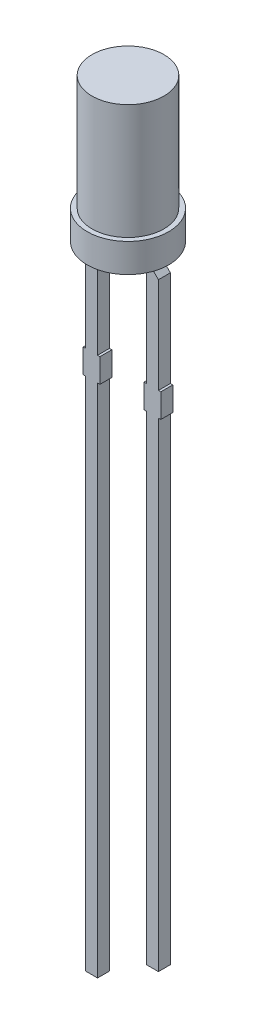
from build123d import *

# Parameters (mm, degrees)
SKETCH1_R          = 1.7
EXTRUDE1_DEPTH     = 1.2
SKETCH2_W          = 0.5
SKETCH2_H          = 1
SKETCH2_W_2        = 0.1
SKETCH2_H_2        = 21.5
SKETCH2_H_3        = 20
EXTRUDE2_DEPTH     = 0.25
SKETCH2_3_W        = 1.5
SKETCH2_3_H        = 4.8
SKETCH3_W          = 0.012658228
SKETCH3_H          = 0.013291139
CUT_EXTRUDE1_DEPTH = 0.01


with BuildPart() as part:
    # Sketch1 → Extrude1 (new body)
    with BuildSketch(Plane(origin=(0, 0, 0), x_dir=(1, 0, 0), z_dir=(0, 1, 0))):
        with Locations(Location((0, 0, 0), (0, 0, 270))):  # turned: the seam where the file's is
            Circle(SKETCH1_R)
    extrude(amount=EXTRUDE1_DEPTH)

    # Sketch2 → Extrude2 (add, symmetric)
    with BuildSketch(Plane.XY):
        Polygon((-0.52, -0.5), (-0.52, 0), (-1.02, 0), (-1.52, -0.5), (-1.52, -4.5), (-1.02, -4.5), (-1.02, -0.5), align=None)
        with Locations((-1.27, -5)):
            Rectangle(SKETCH2_W, SKETCH2_H)
        with Locations((-0.97, -5)):
            Rectangle(SKETCH2_W_2, SKETCH2_H)
        with Locations((-1.57, -5)):
            Rectangle(SKETCH2_W_2, SKETCH2_H)
        with Locations((-1.27, -16.25)):
            Rectangle(SKETCH2_W, SKETCH2_H_2)
        with Locations((1.27, -5)):
            Rectangle(SKETCH2_W, SKETCH2_H)
        Polygon((1.02, -0.5), (1.02, -4.5), (1.52, -4.5), (1.52, -0.5), (1.02, 0), (0.52, 0), (0.52, -0.5), align=None)
        with Locations((1.57, -5)):
            Rectangle(SKETCH2_W_2, SKETCH2_H)
        with Locations((0.97, -5)):
            Rectangle(SKETCH2_W_2, SKETCH2_H)
        with Locations((1.27, -15.5)):
            Rectangle(SKETCH2_W, SKETCH2_H_3)
    extrude(amount=EXTRUDE2_DEPTH, both=True)

    # Sketch2_3 → Revolve1 (revolve)
    with BuildSketch(Plane.XY, mode=Mode.PRIVATE) as revolve1_sk:
        with Locations((0.75, 3.6)):
            Rectangle(SKETCH2_3_W, SKETCH2_3_H)
    revolve(revolve1_sk.sketch.rotate(Axis((0, 1.2, 0), (0, 1, 0)), 270), axis=Axis((0, 1.2, 0), (0, 1, 0)))  # turned: the seam where the file's is

    # Sketch3 → Cut-Extrude1 (cut)
    with BuildSketch(Plane.XZ):
        Polygon((0.287314412, 0.212658228), (0.299043051, 0.25), (0.311414491, 0.25), (0.319622561, 0.224831883), (0.327385615, 0.25), (0.340251517, 0.25), (0.351871374, 0.212658228), (0.339282371, 0.212658228), (0.33278514, 0.238399921), (0.32457707, 0.212658228), (0.313827466, 0.212658228), (0.305668843, 0.238399921), (0.299260615, 0.212658228), align=None)
        Polygon((0.220225805, 0.212658228), (0.231954444, 0.25), (0.244325884, 0.25), (0.252533953, 0.224831883), (0.260297007, 0.25), (0.273162909, 0.25), (0.284782767, 0.212658228), (0.272193763, 0.212658228), (0.265696532, 0.238399921), (0.257488463, 0.212658228), (0.246738858, 0.212658228), (0.238580235, 0.238399921), (0.232172007, 0.212658228), align=None)
        Polygon((0.153137197, 0.212658228), (0.164865836, 0.25), (0.177237276, 0.25), (0.185445346, 0.224831883), (0.193208399, 0.25), (0.206074301, 0.25), (0.217694159, 0.212658228), (0.205105156, 0.212658228), (0.198607925, 0.238399921), (0.190399855, 0.212658228), (0.179650251, 0.212658228), (0.171491627, 0.238399921), (0.165083399, 0.212658228), align=None)
        with Locations((0.139213146, 0.24335443)):
            Rectangle(SKETCH3_W, SKETCH3_H)
        with BuildLine():
            add(Edge.make_bspline(
                [(0.080985298, 0.234414557), (0.081003562, 0.235025614), (0.081039427, 0.236225526), (0.081344008, 0.237979509), (0.08184177, 0.239641151), (0.082523939, 0.241222509), (0.083430933, 0.242700192), (0.08450844, 0.244109475), (0.085814397, 0.245401456), (0.087282915, 0.246620837), (0.088931879, 0.247712034), (0.09073319, 0.248662103), (0.09266835, 0.249474462), (0.09474536, 0.250140307), (0.096968149, 0.250635691), (0.099327037, 0.25099735), (0.101823712, 0.251234103), (0.103535505, 0.251255074), (0.104412909, 0.251265823)],
                knots=[0, 0, 0, 0, 0.907421153, 1.781872267, 2.635683434, 3.480115191, 4.332689235, 5.205575272, 6.109500117, 7.055808355, 8.037942167, 9.041423561, 10.07750834, 11.152467461, 12.277657752, 13.45734338, 14.696726425, 16, 16, 16, 16], degree=3))
            add(Edge.make_bspline(
                [(0.104412909, 0.251265823), (0.105421901, 0.25125219), (0.107375994, 0.251225789), (0.110209778, 0.251033102), (0.112841512, 0.250689127), (0.115290385, 0.250210837), (0.117592536, 0.249609194), (0.119809208, 0.248963872), (0.121949854, 0.248231582), (0.1233364, 0.247681514), (0.124023273, 0.247409019)],
                knots=[0, 0, 0, 0, 1.203182053, 2.33017619, 3.384818652, 4.366208123, 5.30340534, 6.221361684, 7.118890722, 8, 8, 8, 8], degree=3))
            Line((0.124023273, 0.247409019), (0.124023273, 0.235443038))
            Line((0.124023273, 0.235443038), (0.122599222, 0.235443038))
            add(Edge.make_bspline(
                [(0.122599222, 0.235443038), (0.121916441, 0.235983519), (0.120554886, 0.237061309), (0.118341407, 0.238445486), (0.116011901, 0.239631991), (0.113592704, 0.240623303), (0.11114202, 0.24141111), (0.108707486, 0.241974562), (0.106322995, 0.242344245), (0.104743834, 0.242385025), (0.103967893, 0.242405063)],
                knots=[0, 0, 0, 0, 1.030738938, 2.055426519, 3.085610749, 4.123842265, 5.148648843, 6.130724483, 7.081507926, 8, 8, 8, 8], degree=3))
            add(Edge.make_bspline(
                [(0.103967893, 0.242405063), (0.10375352, 0.242404413), (0.103294564, 0.242403021), (0.10255999, 0.242342363), (0.101731818, 0.242278441), (0.100841449, 0.242180384), (0.099947847, 0.242064812), (0.099117723, 0.241891578), (0.098367342, 0.241707002), (0.097914007, 0.24152337), (0.097698115, 0.241435918)],
                knots=[0, 0, 0, 0, 0.806537132, 1.726733348, 2.77251655, 3.932999672, 5.098049949, 6.161349231, 7.124375527, 8, 8, 8, 8], degree=3))
            add(Edge.make_bspline(
                [(0.097698115, 0.241435918), (0.097458372, 0.2413218), (0.096987225, 0.241097534), (0.09633596, 0.240690579), (0.095750717, 0.240243207), (0.095220366, 0.23976234), (0.094789169, 0.239180846), (0.094478588, 0.238481211), (0.094306303, 0.237656564), (0.094286767, 0.237068983), (0.094276437, 0.236758307)],
                knots=[0, 0, 0, 0, 1.02474257, 2.013837243, 2.958431669, 3.867978675, 4.769292696, 5.732237074, 6.800947934, 8, 8, 8, 8], degree=3))
            add(Edge.make_bspline(
                [(0.094276437, 0.236758307), (0.094292168, 0.236485374), (0.094323099, 0.235948707), (0.094613852, 0.235184492), (0.095055876, 0.234474424), (0.095695583, 0.233841756), (0.096502423, 0.2332787), (0.097467916, 0.232773318), (0.098604841, 0.23235544), (0.099423448, 0.232136504), (0.099853969, 0.232021361)],
                knots=[0, 0, 0, 0, 0.825427492, 1.623033598, 2.45033906, 3.348940377, 4.33183287, 5.428402891, 6.647546779, 8, 8, 8, 8], degree=3))
            add(Edge.make_bspline(
                [(0.099853969, 0.232021361), (0.100838589, 0.231798758), (0.102856195, 0.231342619), (0.105926102, 0.230748892), (0.108995453, 0.230135957), (0.110973582, 0.2295288), (0.111938621, 0.229232595)],
                knots=[0, 0, 0, 0, 0.976118991, 2.000185432, 3.024380873, 4, 4, 4, 4], degree=3))
            add(Edge.make_bspline(
                [(0.111938621, 0.229232595), (0.112457697, 0.229055734), (0.113468128, 0.228711456), (0.114917724, 0.228135132), (0.116239348, 0.227482565), (0.117468118, 0.226821546), (0.11856445, 0.226081517), (0.119561767, 0.225315138), (0.120438097, 0.224488735), (0.121201316, 0.223613989), (0.121872749, 0.222695808), (0.122449454, 0.221722237), (0.122929965, 0.220689013), (0.123341661, 0.219611314), (0.123647274, 0.218474046), (0.123858492, 0.217285838), (0.124007524, 0.216044095), (0.124017952, 0.215196927), (0.124023273, 0.214764636)],
                knots=[0, 0, 0, 0, 1.287376879, 2.505999703, 3.65855109, 4.746193839, 5.778582289, 6.760029101, 7.696159662, 8.601061861, 9.48181646, 10.363080883, 11.252765705, 12.153987336, 13.068239035, 14.012364187, 14.985753787, 16, 16, 16, 16], degree=3))
            add(Edge.make_bspline(
                [(0.124023273, 0.214764636), (0.124004623, 0.214186563), (0.123967919, 0.213048925), (0.123667194, 0.211384414), (0.123153939, 0.209810005), (0.122460759, 0.208308427), (0.121547013, 0.206901295), (0.120450951, 0.205562552), (0.119145796, 0.204316304), (0.117653133, 0.203166986), (0.116009709, 0.202127583), (0.114242707, 0.201209229), (0.112353281, 0.200456005), (0.110363338, 0.19981539), (0.108253642, 0.199339192), (0.106035157, 0.198979403), (0.103698226, 0.198772903), (0.10210252, 0.198747265), (0.101287909, 0.198734177)],
                knots=[0, 0, 0, 0, 0.894901293, 1.761149761, 2.608783409, 3.453876344, 4.314933854, 5.200038827, 6.12799933, 7.103249695, 8.113098521, 9.136064399, 10.182719798, 11.259667356, 12.370545059, 13.528828137, 14.738461593, 16, 16, 16, 16], degree=3))
            add(Edge.make_bspline(
                [(0.101287909, 0.198734177), (0.100453583, 0.198745374), (0.098786346, 0.198767747), (0.09629536, 0.198955232), (0.093816653, 0.199238483), (0.09138087, 0.19963821), (0.089039617, 0.200147038), (0.08683131, 0.200690017), (0.084791825, 0.201310212), (0.083504962, 0.201787235), (0.082884032, 0.202017405)],
                knots=[0, 0, 0, 0, 1.065379838, 2.128953261, 3.188461447, 4.250817766, 5.279613205, 6.247547721, 7.154416075, 8, 8, 8, 8], degree=3))
            Line((0.082884032, 0.202017405), (0.082884032, 0.213291139))
            Line((0.082884032, 0.213291139), (0.084298194, 0.213291139))
            add(Edge.make_bspline(
                [(0.084298194, 0.213291139), (0.084834674, 0.212891037), (0.085931789, 0.212072818), (0.087761165, 0.21102983), (0.089743195, 0.210055073), (0.091875646, 0.209194176), (0.094111916, 0.208483876), (0.096400689, 0.207969354), (0.098714222, 0.207649792), (0.100265017, 0.207613226), (0.101040678, 0.207594937)],
                knots=[0, 0, 0, 0, 0.89224925, 1.824673196, 2.804309561, 3.838364047, 4.890042674, 5.931526337, 6.965412421, 8, 8, 8, 8], degree=3))
            add(Edge.make_bspline(
                [(0.101040678, 0.207594937), (0.101588328, 0.207607042), (0.102683201, 0.207631242), (0.104320404, 0.207805869), (0.1059378, 0.20814174), (0.106959249, 0.208548908), (0.107468684, 0.208751978)],
                knots=[0, 0, 0, 0, 0.998993879, 1.997209027, 3.00113285, 4, 4, 4, 4], degree=3))
            add(Edge.make_bspline(
                [(0.107468684, 0.208751978), (0.107685424, 0.208852719), (0.108118759, 0.209054135), (0.10872226, 0.209440298), (0.109273912, 0.209905157), (0.109774415, 0.210431354), (0.110198443, 0.211016021), (0.110517273, 0.211650901), (0.110697683, 0.21233189), (0.110720601, 0.212798974), (0.110732134, 0.213034019)],
                knots=[0, 0, 0, 0, 1.005454979, 2.010239304, 3.005296729, 4.036100111, 5.060531193, 6.034954812, 7.011155677, 8, 8, 8, 8], degree=3))
            add(Edge.make_bspline(
                [(0.110732134, 0.213034019), (0.110714737, 0.213352984), (0.110681492, 0.213962498), (0.110381493, 0.214819347), (0.109882659, 0.215550902), (0.109306109, 0.216047399), (0.10874762, 0.216396779), (0.108227361, 0.216649399), (0.107627636, 0.21690611), (0.106938911, 0.217150709), (0.106171344, 0.217397732), (0.105316883, 0.217635067), (0.104375579, 0.217859847), (0.103717634, 0.218002923), (0.103374539, 0.218077532)],
                knots=[0, 0, 0, 0, 1.174343879, 2.244064321, 3.303704314, 4.407076671, 5.02483983, 5.732197225, 6.53898402, 7.431906431, 8.428480183, 9.514816237, 10.704066255, 12, 12, 12, 12], degree=3))
            add(Edge.make_bspline(
                [(0.103374539, 0.218077532), (0.102458226, 0.218265892), (0.100657875, 0.218635978), (0.097955337, 0.219183126), (0.09520881, 0.219839385), (0.093373535, 0.220403991), (0.09241726, 0.22069818)],
                knots=[0, 0, 0, 0, 0.995788186, 1.956503735, 2.935230479, 4, 4, 4, 4], degree=3))
            add(Edge.make_bspline(
                [(0.09241726, 0.22069818), (0.091943982, 0.220857801), (0.091018173, 0.221170045), (0.089697874, 0.221713204), (0.088474288, 0.222300133), (0.087340971, 0.222921117), (0.086303288, 0.223592334), (0.085360143, 0.224305001), (0.084511164, 0.225057392), (0.08376679, 0.225865252), (0.083102411, 0.226720426), (0.082546239, 0.227645733), (0.082048447, 0.228617497), (0.081671869, 0.229664219), (0.081359615, 0.230763482), (0.081148743, 0.23192945), (0.081001562, 0.233151559), (0.08099078, 0.233988858), (0.080985298, 0.234414557)],
                knots=[0, 0, 0, 0, 1.237326419, 2.420410185, 3.534642089, 4.598489486, 5.620241961, 6.59385002, 7.525152549, 8.426792174, 9.312230456, 10.203151844, 11.098070343, 12.012931196, 12.954244379, 13.926618287, 14.945853925, 16, 16, 16, 16], degree=3))
        make_face()
        with BuildLine():
            Line((0.034782767, 0.25), (0.046808083, 0.25))
            Line((0.046808083, 0.25), (0.046808083, 0.246083861))
            add(Edge.make_bspline(
                [(0.046808083, 0.246083861), (0.04735468, 0.246488258), (0.048408511, 0.247267931), (0.04999579, 0.248306461), (0.05150494, 0.249198673), (0.052970116, 0.249960231), (0.054473255, 0.250566317), (0.056092322, 0.250975507), (0.05784312, 0.251226869), (0.059056655, 0.25125255), (0.059683874, 0.251265823)],
                knots=[0, 0, 0, 0, 1.150945962, 2.219006967, 3.209666795, 4.118194914, 5.012574058, 5.946577101, 6.93868214, 8, 8, 8, 8], degree=3))
            add(Edge.make_bspline(
                [(0.059683874, 0.251265823), (0.060192012, 0.251254349), (0.061181502, 0.251232006), (0.062620652, 0.251061145), (0.063971635, 0.250786941), (0.065236053, 0.250402738), (0.066410903, 0.249901222), (0.067482743, 0.249265405), (0.068484032, 0.248549048), (0.069375005, 0.247695865), (0.070182778, 0.246746906), (0.070874064, 0.245680701), (0.071462916, 0.244514232), (0.071933466, 0.243238307), (0.072311011, 0.241859154), (0.072572977, 0.240369531), (0.072733273, 0.238775967), (0.072749243, 0.237678402), (0.07275745, 0.23711432)],
                knots=[0, 0, 0, 0, 1.108959949, 2.159465255, 3.158589008, 4.114545495, 5.039534357, 5.93921201, 6.830099133, 7.720870013, 8.624681761, 9.544731627, 10.487599671, 11.471264588, 12.508152322, 13.604835107, 14.769030043, 16, 16, 16, 16], degree=3))
            Line((0.07275745, 0.23711432), (0.07275745, 0.212658228))
            Line((0.07275745, 0.212658228), (0.060732134, 0.212658228))
            Line((0.060732134, 0.212658228), (0.060732134, 0.231447785))
            add(Edge.make_bspline(
                [(0.060732134, 0.231447785), (0.060731316, 0.23190602), (0.060729751, 0.232783128), (0.060688581, 0.234036031), (0.060628131, 0.235170118), (0.060558779, 0.236191132), (0.06043227, 0.237114507), (0.060243416, 0.237947588), (0.060008003, 0.238707389), (0.059775843, 0.23916074), (0.059664096, 0.239378956)],
                knots=[0, 0, 0, 0, 1.361401701, 2.605856924, 3.723918663, 4.735739235, 5.645738665, 6.489217889, 7.27279937, 8, 8, 8, 8], degree=3))
            add(Edge.make_bspline(
                [(0.059664096, 0.239378956), (0.059549091, 0.239578309), (0.059323003, 0.239970219), (0.058862871, 0.240473375), (0.05832345, 0.24089525), (0.057684848, 0.2412243), (0.056940064, 0.241469552), (0.056079635, 0.241659838), (0.055083764, 0.241745776), (0.05438003, 0.241763022), (0.05400745, 0.241772152)],
                knots=[0, 0, 0, 0, 0.849004071, 1.669068917, 2.503060811, 3.370079215, 4.310762265, 5.396376419, 6.621555549, 8, 8, 8, 8], degree=3))
            add(Edge.make_bspline(
                [(0.05400745, 0.241772152), (0.053736979, 0.241762232), (0.053181271, 0.241741852), (0.052322544, 0.241646081), (0.051427914, 0.241446502), (0.05016858, 0.241124029), (0.048585975, 0.240527102), (0.047406208, 0.239850529), (0.046808083, 0.239507516)],
                knots=[0, 0, 0, 0, 0.638062719, 1.310959128, 2.033463623, 2.796942592, 4.376095945, 6, 6, 6, 6], degree=3))
            Line((0.046808083, 0.239507516), (0.046808083, 0.212658228))
            Line((0.046808083, 0.212658228), (0.034782767, 0.212658228))
            Line((0.034782767, 0.212658228), (0.034782767, 0.25))
        make_face()
        with BuildLine():
            Line((-0.013951411, 0.25), (-0.001926094, 0.25))
            Line((-0.001926094, 0.25), (-0.001926094, 0.231210443))
            add(Edge.make_bspline(
                [(-0.001926094, 0.231210443), (-0.001913591, 0.230445448), (-0.001888605, 0.228916703), (-0.00175033, 0.227035156), (-0.001558086, 0.225614386), (-0.001374316, 0.224698591), (-0.001158381, 0.223924533), (-0.00095225, 0.223481652), (-0.000858056, 0.223279272)],
                knots=[0, 0, 0, 0, 1.709111167, 3.415443484, 4.21113913, 4.910175115, 5.501990373, 6, 6, 6, 6], degree=3))
            add(Edge.make_bspline(
                [(-0.000858056, 0.223279272), (-0.000735826, 0.223080241), (-0.000496176, 0.222690012), (-2.75e-05, 0.222183573), (0.000519391, 0.221768889), (0.001154979, 0.221429156), (0.001899034, 0.221189562), (0.002760993, 0.221013185), (0.003751085, 0.220907908), (0.004455499, 0.220893631), (0.004828257, 0.220886076)],
                knots=[0, 0, 0, 0, 0.860202684, 1.686548532, 2.528236983, 3.382486038, 4.33249885, 5.401154041, 6.624757403, 8, 8, 8, 8], degree=3))
            add(Edge.make_bspline(
                [(0.004828257, 0.220886076), (0.005393702, 0.220916126), (0.006547549, 0.220977447), (0.007985204, 0.22131078), (0.009143873, 0.221740762), (0.010072732, 0.22211598), (0.011026593, 0.22260303), (0.011666364, 0.222963751), (0.011997956, 0.223150712)],
                knots=[0, 0, 0, 0, 1.33818541, 2.730705359, 3.468371228, 4.262126284, 5.099261778, 6, 6, 6, 6], degree=3))
            Line((0.011997956, 0.223150712), (0.011997956, 0.25))
            Line((0.011997956, 0.25), (0.024023273, 0.25))
            Line((0.024023273, 0.25), (0.024023273, 0.212658228))
            Line((0.024023273, 0.212658228), (0.011997956, 0.212658228))
            Line((0.011997956, 0.212658228), (0.011997956, 0.216574367))
            add(Edge.make_bspline(
                [(0.011997956, 0.216574367), (0.011469253, 0.216171291), (0.010440101, 0.21538668), (0.008850482, 0.21436647), (0.007308533, 0.213467085), (0.005782028, 0.212710677), (0.004224551, 0.21210729), (0.002593171, 0.211701795), (0.000884968, 0.211429894), (-0.000283389, 0.211405047), (-0.000877835, 0.211392405)],
                knots=[0, 0, 0, 0, 1.126119141, 2.192057864, 3.198061997, 4.149848529, 5.076251285, 6.021887753, 6.99356175, 8, 8, 8, 8], degree=3))
            add(Edge.make_bspline(
                [(-0.000877835, 0.211392405), (-0.001375967, 0.211405105), (-0.00234841, 0.211429898), (-0.003765835, 0.211584674), (-0.005101388, 0.211860286), (-0.00634808, 0.212258214), (-0.007515924, 0.212753894), (-0.00860276, 0.213355883), (-0.009595684, 0.214087524), (-0.01050976, 0.214917493), (-0.01132931, 0.215863142), (-0.012027765, 0.216927831), (-0.012629946, 0.218096291), (-0.013104579, 0.21937761), (-0.013500241, 0.220760746), (-0.013752622, 0.222260061), (-0.013931449, 0.223865003), (-0.013944624, 0.224973078), (-0.013951411, 0.225543908)],
                knots=[0, 0, 0, 0, 1.08828964, 2.12453497, 3.110382522, 4.062402335, 4.978696626, 5.878225494, 6.769849763, 7.667011675, 8.57076823, 9.495541561, 10.442454184, 11.436213583, 12.475881554, 13.580560132, 14.753614518, 16, 16, 16, 16], degree=3))
            Line((-0.013951411, 0.225543908), (-0.013951411, 0.25))
        make_face()
        Polygon((-0.061419765, 0.25), (-0.025343816, 0.25), (-0.025343816, 0.2), (-0.038002044, 0.2), (-0.038002044, 0.240506329), (-0.061419765, 0.240506329), align=None)
        Polygon((-0.105090651, 0.25), (-0.069014702, 0.25), (-0.069014702, 0.2), (-0.105090651, 0.2), (-0.105090651, 0.209493671), (-0.08167293, 0.209493671), (-0.08167293, 0.21835443), (-0.103191917, 0.21835443), (-0.103191917, 0.227848101), (-0.08167293, 0.227848101), (-0.08167293, 0.240506329), (-0.105090651, 0.240506329), align=None)
        with BuildLine():
            add(Edge.make_bspline(
                [(-0.163318499, 0.225049446), (-0.163308842, 0.225623291), (-0.163289716, 0.226759734), (-0.16314212, 0.228442137), (-0.162879107, 0.230074975), (-0.162539517, 0.231667099), (-0.162078264, 0.233206563), (-0.161537407, 0.234710351), (-0.160882584, 0.236163098), (-0.160130158, 0.237563815), (-0.159305421, 0.238899867), (-0.158418047, 0.240159971), (-0.157495157, 0.24135158), (-0.156500501, 0.242449027), (-0.15546091, 0.243470037), (-0.154373146, 0.244415444), (-0.153220614, 0.245267159), (-0.152417032, 0.245778602), (-0.152015097, 0.246034415)],
                knots=[0, 0, 0, 0, 1.105570398, 2.18947457, 3.250358341, 4.290584537, 5.323553275, 6.344225964, 7.367641686, 8.3905646, 9.405808457, 10.390761353, 11.358902336, 12.307789878, 13.241960776, 14.165076779, 15.082208636, 16, 16, 16, 16], degree=3))
            add(Edge.make_bspline(
                [(-0.152015097, 0.246034415), (-0.151395504, 0.246390575), (-0.150153155, 0.247104714), (-0.148160926, 0.247937633), (-0.146100122, 0.248644745), (-0.143920531, 0.249151465), (-0.141601171, 0.249536382), (-0.139098765, 0.249810468), (-0.136395312, 0.249963219), (-0.134527816, 0.24998746), (-0.133561775, 0.25)],
                knots=[0, 0, 0, 0, 0.896321744, 1.797216976, 2.705381885, 3.628777036, 4.602292017, 5.655629376, 6.787275635, 8, 8, 8, 8], degree=3))
            Line((-0.133561775, 0.25), (-0.115850145, 0.25))
            Line((-0.115850145, 0.25), (-0.115850145, 0.2))
            Line((-0.115850145, 0.2), (-0.134066126, 0.2))
            add(Edge.make_bspline(
                [(-0.134066126, 0.2), (-0.135055474, 0.200008405), (-0.136963804, 0.200024617), (-0.139722462, 0.200232081), (-0.142273631, 0.200534963), (-0.144618421, 0.200982055), (-0.146769646, 0.201539346), (-0.148728292, 0.202233612), (-0.150536408, 0.20297992), (-0.151625676, 0.203617197), (-0.152153547, 0.203926028)],
                knots=[0, 0, 0, 0, 1.267083275, 2.444046388, 3.541868212, 4.55639609, 5.499737919, 6.385160515, 7.217431253, 8, 8, 8, 8], degree=3))
            add(Edge.make_bspline(
                [(-0.152153547, 0.203926028), (-0.152579023, 0.204194299), (-0.153425086, 0.204727756), (-0.154625693, 0.205618682), (-0.155740407, 0.20659672), (-0.156804658, 0.20762263), (-0.157794567, 0.208724073), (-0.158716167, 0.209893427), (-0.159568075, 0.211132474), (-0.160347057, 0.212437208), (-0.161057464, 0.213802234), (-0.161652117, 0.215238764), (-0.162176792, 0.216728029), (-0.16257956, 0.21828251), (-0.162928517, 0.219886428), (-0.163145884, 0.2215571), (-0.16328919, 0.223283344), (-0.163308647, 0.224455789), (-0.163318499, 0.225049446)],
                knots=[0, 0, 0, 0, 0.964065863, 1.917049184, 2.86229036, 3.805247319, 4.749389377, 5.698846072, 6.657678277, 7.629829384, 8.610569287, 9.604676042, 10.607940105, 11.6349849, 12.681042988, 13.752616828, 14.862056989, 16, 16, 16, 16], degree=3))
        make_face()
        with BuildLine():
            add(Edge.make_bspline(
                [(-0.15002736, 0.224970332), (-0.150005709, 0.224181117), (-0.149963902, 0.222657217), (-0.149611205, 0.220459395), (-0.14904158, 0.21843792), (-0.148372734, 0.216881712), (-0.147704038, 0.215745054), (-0.147140276, 0.214945918), (-0.146515443, 0.214188819), (-0.145820139, 0.213484399), (-0.145052547, 0.212830881), (-0.144221917, 0.212216425), (-0.143321897, 0.211652102), (-0.142685381, 0.211322099), (-0.142363199, 0.211155063)],
                knots=[0, 0, 0, 0, 1.694683197, 3.272273219, 4.767406206, 6.197615014, 6.895990032, 7.597410435, 8.296503208, 9.002591366, 9.720792421, 10.460154445, 11.220583224, 12, 12, 12, 12], degree=3))
            add(Edge.make_bspline(
                [(-0.142363199, 0.211155063), (-0.142025731, 0.211001806), (-0.141356847, 0.21069804), (-0.140321709, 0.210330997), (-0.139275359, 0.210049833), (-0.138178245, 0.209813621), (-0.136939865, 0.209675053), (-0.135478619, 0.209568715), (-0.133750283, 0.209500251), (-0.132506985, 0.209495966), (-0.131841047, 0.209493671)],
                knots=[0, 0, 0, 0, 0.826913061, 1.638999358, 2.447478739, 3.243919028, 4.140906711, 5.225381046, 6.513851968, 8, 8, 8, 8], degree=3))
            Line((-0.131841047, 0.209493671), (-0.128508373, 0.209493671))
            Line((-0.128508373, 0.209493671), (-0.128508373, 0.240506329))
            Line((-0.128508373, 0.240506329), (-0.131841047, 0.240506329))
            add(Edge.make_bspline(
                [(-0.131841047, 0.240506329), (-0.132220142, 0.240503806), (-0.13295201, 0.240498936), (-0.134010237, 0.240479384), (-0.134992618, 0.240449226), (-0.135896293, 0.240413305), (-0.136724361, 0.240355853), (-0.137468278, 0.240271555), (-0.138139453, 0.240199361), (-0.138923271, 0.240065801), (-0.139849845, 0.239857574), (-0.140930478, 0.239518528), (-0.142000744, 0.239093318), (-0.142695031, 0.238750836), (-0.143045556, 0.238577927)],
                knots=[0, 0, 0, 0, 1.186775798, 2.291144404, 3.313233901, 4.263515562, 5.122260739, 5.910868134, 6.60717912, 7.234883681, 8.398964994, 9.577230746, 10.776813768, 12, 12, 12, 12], degree=3))
            add(Edge.make_bspline(
                [(-0.143045556, 0.238577927), (-0.143337413, 0.238406189), (-0.143911382, 0.238068447), (-0.144733454, 0.237515516), (-0.145476824, 0.236898016), (-0.146179855, 0.236256467), (-0.146806288, 0.23556124), (-0.147392934, 0.234836), (-0.147898062, 0.234054804), (-0.14852056, 0.232958039), (-0.149130426, 0.231441354), (-0.149650806, 0.229458082), (-0.149969063, 0.227278077), (-0.15000743, 0.225759286), (-0.15002736, 0.224970332)],
                knots=[0, 0, 0, 0, 0.755109416, 1.485004392, 2.205961541, 2.908125208, 3.605307969, 4.290649036, 4.985852759, 5.676964147, 7.100721462, 8.614478074, 10.241350405, 12, 12, 12, 12], degree=3))
        make_face(mode=Mode.SUBTRACT)
        with Locations((-0.179141284, 0.24335443)):
            Rectangle(SKETCH3_W, SKETCH3_H)
        with BuildLine():
            add(Edge.make_bspline(
                [(-0.216463278, 0.251265823), (-0.215668225, 0.25125491), (-0.214107664, 0.251233489), (-0.211821942, 0.250995138), (-0.20963954, 0.250635904), (-0.207565731, 0.250126818), (-0.20561245, 0.249448647), (-0.203771924, 0.24863964), (-0.202077243, 0.247630737), (-0.201045378, 0.246842266), (-0.200531711, 0.246449763)],
                knots=[0, 0, 0, 0, 1.123606455, 2.205459211, 3.245124445, 4.248821949, 5.220056174, 6.165006393, 7.086533249, 8, 8, 8, 8], degree=3))
            add(Edge.make_bspline(
                [(-0.200531711, 0.246449763), (-0.200055838, 0.246022376), (-0.19910593, 0.245169254), (-0.197872964, 0.243683541), (-0.196811421, 0.242042019), (-0.195918644, 0.240240907), (-0.195203183, 0.238282543), (-0.194691616, 0.236160212), (-0.194381993, 0.233879822), (-0.19434841, 0.232305855), (-0.194331157, 0.231497231)],
                knots=[0, 0, 0, 0, 0.916457077, 1.82937027, 2.759194969, 3.714948755, 4.706655623, 5.743329475, 6.840637961, 8, 8, 8, 8], degree=3))
            add(Edge.make_bspline(
                [(-0.194331157, 0.231497231), (-0.194350538, 0.230645617), (-0.194388099, 0.228995077), (-0.194719979, 0.226608984), (-0.195254785, 0.224400143), (-0.196023564, 0.222374189), (-0.196988785, 0.220527593), (-0.198121031, 0.218841676), (-0.199431294, 0.217320214), (-0.200434864, 0.216447494), (-0.20093717, 0.21601068)],
                knots=[0, 0, 0, 0, 1.171797512, 2.271099083, 3.308930235, 4.294129479, 5.24602549, 6.17106565, 7.084581485, 8, 8, 8, 8], degree=3))
            add(Edge.make_bspline(
                [(-0.20093717, 0.21601068), (-0.201450127, 0.21562645), (-0.202482236, 0.214853347), (-0.204183658, 0.213902042), (-0.205997503, 0.213107945), (-0.207908371, 0.212469585), (-0.209895864, 0.211992277), (-0.211927641, 0.211645944), (-0.213999542, 0.211431603), (-0.215394732, 0.211405534), (-0.216097376, 0.211392405)],
                knots=[0, 0, 0, 0, 0.952046378, 1.915591786, 2.889970712, 3.892742799, 4.906722985, 5.925995921, 6.955492795, 8, 8, 8, 8], degree=3))
            add(Edge.make_bspline(
                [(-0.216097376, 0.211392405), (-0.216720778, 0.211400604), (-0.217946598, 0.211416725), (-0.219746018, 0.211582027), (-0.221474997, 0.211832996), (-0.223128457, 0.212202282), (-0.224711955, 0.21266309), (-0.226239025, 0.213179121), (-0.227718641, 0.213746737), (-0.228668963, 0.214188876), (-0.229141284, 0.214408623)],
                knots=[0, 0, 0, 0, 1.107549047, 2.177816721, 3.208424937, 4.210433793, 5.185680559, 6.13785309, 7.074491882, 8, 8, 8, 8], degree=3))
            Line((-0.229141284, 0.214408623), (-0.229141284, 0.224683544))
            Line((-0.229141284, 0.224683544), (-0.227470002, 0.224683544))
            add(Edge.make_bspline(
                [(-0.227470002, 0.224683544), (-0.227219714, 0.224475601), (-0.226677201, 0.224024875), (-0.225793785, 0.223301581), (-0.224708625, 0.222551436), (-0.223885111, 0.222104124), (-0.223445082, 0.221865111)],
                knots=[0, 0, 0, 0, 0.792743043, 1.718305972, 2.780820752, 4, 4, 4, 4], degree=3))
            add(Edge.make_bspline(
                [(-0.223445082, 0.221865111), (-0.222980614, 0.221645792), (-0.222027659, 0.221195811), (-0.220756055, 0.220757117), (-0.219654466, 0.220494433), (-0.218747636, 0.22036165), (-0.217780487, 0.220268221), (-0.217112914, 0.220258276), (-0.216769844, 0.220253165)],
                knots=[0, 0, 0, 0, 1.332360773, 2.733622135, 3.480580446, 4.268165618, 5.10999921, 6, 6, 6, 6], degree=3))
            add(Edge.make_bspline(
                [(-0.216769844, 0.220253165), (-0.216387025, 0.22026283), (-0.215645138, 0.220281561), (-0.214564955, 0.220421585), (-0.213552646, 0.220655631), (-0.212608627, 0.220994603), (-0.211731711, 0.221420486), (-0.210921699, 0.221941209), (-0.210174983, 0.222552845), (-0.209515513, 0.223273661), (-0.208919106, 0.224063531), (-0.208409517, 0.224930614), (-0.207953286, 0.225853907), (-0.207605817, 0.226856133), (-0.207325948, 0.22792052), (-0.207131483, 0.229052081), (-0.207010504, 0.230251836), (-0.206996545, 0.23107499), (-0.206989385, 0.231497231)],
                knots=[0, 0, 0, 0, 1.087372478, 2.107277257, 3.088614887, 4.033572876, 4.950837204, 5.852283781, 6.763600506, 7.684681617, 8.621202104, 9.570420019, 10.537986648, 11.542161979, 12.577980734, 13.661919757, 14.800668594, 16, 16, 16, 16], degree=3))
            add(Edge.make_bspline(
                [(-0.206989385, 0.231497231), (-0.206996773, 0.231929309), (-0.207011126, 0.232768815), (-0.207127883, 0.233989621), (-0.207335828, 0.235130337), (-0.207621452, 0.236192997), (-0.207983626, 0.237176006), (-0.208436185, 0.238074704), (-0.208954363, 0.238903108), (-0.209576642, 0.239634414), (-0.210258584, 0.240292574), (-0.21101603, 0.240860642), (-0.211845649, 0.241334714), (-0.21273674, 0.241736946), (-0.21370326, 0.242026145), (-0.214731528, 0.242244491), (-0.215826306, 0.242388769), (-0.216581483, 0.24239955), (-0.216967629, 0.242405063)],
                knots=[0, 0, 0, 0, 1.230336593, 2.390482092, 3.487897344, 4.52859895, 5.520747884, 6.465347575, 7.38981449, 8.296085817, 9.192433006, 10.084246191, 10.984321635, 11.908883871, 12.862027947, 13.850751296, 14.901019963, 16, 16, 16, 16], degree=3))
            add(Edge.make_bspline(
                [(-0.216967629, 0.242405063), (-0.217330511, 0.242400688), (-0.218037937, 0.24239216), (-0.219071437, 0.242287383), (-0.22005019, 0.242133997), (-0.220966761, 0.24191402), (-0.221818127, 0.241657745), (-0.222596294, 0.241371273), (-0.223302782, 0.241069709), (-0.223733427, 0.240835832), (-0.223939544, 0.240723892)],
                knots=[0, 0, 0, 0, 1.201052708, 2.34140671, 3.435973211, 4.479046096, 5.459661032, 6.378175262, 7.223757638, 8, 8, 8, 8], degree=3))
            add(Edge.make_bspline(
                [(-0.223939544, 0.240723892), (-0.224289646, 0.240508945), (-0.22496693, 0.240093124), (-0.225886294, 0.239392341), (-0.226708728, 0.238685211), (-0.227220984, 0.238207102), (-0.227470002, 0.237974684)],
                knots=[0, 0, 0, 0, 1.098601379, 2.125273733, 3.088655601, 4, 4, 4, 4], degree=3))
            Line((-0.227470002, 0.237974684), (-0.229141284, 0.237974684))
            Line((-0.229141284, 0.237974684), (-0.229141284, 0.248328718))
            add(Edge.make_bspline(
                [(-0.229141284, 0.248328718), (-0.228668589, 0.248547465), (-0.227723086, 0.248985012), (-0.226265796, 0.249561948), (-0.22477181, 0.250046028), (-0.223247623, 0.250497569), (-0.221661582, 0.25084175), (-0.220000066, 0.251088311), (-0.218259317, 0.251238767), (-0.217070123, 0.251256681), (-0.216463278, 0.251265823)],
                knots=[0, 0, 0, 0, 0.952012952, 1.904254716, 2.862729541, 3.822037426, 4.808956931, 5.82647221, 6.890850784, 8, 8, 8, 8], degree=3))
        make_face()
        with BuildLine():
            add(Edge.make_bspline(
                [(-0.275343816, 0.231348892), (-0.275331468, 0.232101345), (-0.275307399, 0.233568078), (-0.27503774, 0.235703974), (-0.274631351, 0.237721973), (-0.274045085, 0.239615577), (-0.273304889, 0.241394214), (-0.272379419, 0.243039111), (-0.271293917, 0.244565725), (-0.270048398, 0.245960668), (-0.268647797, 0.247209923), (-0.267110706, 0.24830755), (-0.265423793, 0.24921427), (-0.263616637, 0.249970316), (-0.261674311, 0.250554933), (-0.259597202, 0.250961292), (-0.257388634, 0.251229027), (-0.255869425, 0.251253353), (-0.255090651, 0.251265823)],
                knots=[0, 0, 0, 0, 1.120167703, 2.183507516, 3.201345984, 4.182878364, 5.131270247, 6.065524964, 6.98789854, 7.91635504, 8.84481154, 9.778033504, 10.722808862, 11.691211189, 12.691525459, 13.738229926, 14.840575679, 16, 16, 16, 16], degree=3))
            add(Edge.make_bspline(
                [(-0.255090651, 0.251265823), (-0.254311891, 0.251253312), (-0.252792708, 0.251228906), (-0.250583953, 0.25096174), (-0.248504406, 0.250552765), (-0.246559752, 0.249974714), (-0.244755379, 0.249211439), (-0.243070446, 0.248307915), (-0.241533563, 0.247209819), (-0.24013282, 0.245960723), (-0.238887661, 0.24456561), (-0.237800866, 0.243039518), (-0.236879659, 0.241391541), (-0.236120732, 0.239620018), (-0.23555407, 0.2377196), (-0.235142338, 0.235704379), (-0.234874234, 0.233567969), (-0.234849947, 0.232101308), (-0.234837487, 0.231348892)],
                knots=[0, 0, 0, 0, 1.15937715, 2.261678054, 3.308339936, 4.313313916, 5.277148057, 6.221884977, 7.155068972, 8.083487698, 9.011906424, 9.934242473, 10.868459181, 11.818729666, 12.798784262, 13.81658132, 14.879877871, 16, 16, 16, 16], degree=3))
            add(Edge.make_bspline(
                [(-0.234837487, 0.231348892), (-0.234850037, 0.230593176), (-0.234874559, 0.229116662), (-0.235142393, 0.226967288), (-0.235550874, 0.22493674), (-0.23613364, 0.223030465), (-0.236886778, 0.221249227), (-0.237810251, 0.219596133), (-0.238908129, 0.218072746), (-0.240162846, 0.216677663), (-0.241569229, 0.215430399), (-0.243112978, 0.214341347), (-0.244794748, 0.21343695), (-0.246594924, 0.212673068), (-0.248538755, 0.212106795), (-0.250607068, 0.211697717), (-0.25280581, 0.211428762), (-0.254315173, 0.211404745), (-0.255090651, 0.211392405)],
                knots=[0, 0, 0, 0, 1.123883205, 2.195836198, 3.217400301, 4.202580581, 5.156396106, 6.089661422, 7.013912723, 7.944661364, 8.875797629, 9.805201257, 10.748976071, 11.711828658, 12.709674189, 13.755270167, 14.846705509, 16, 16, 16, 16], degree=3))
            add(Edge.make_bspline(
                [(-0.255090651, 0.211392405), (-0.25587602, 0.211404766), (-0.257405102, 0.211428832), (-0.259626808, 0.211696934), (-0.261713728, 0.212103436), (-0.26366304, 0.212686634), (-0.265475915, 0.213442341), (-0.267155953, 0.21435967), (-0.268691607, 0.215460699), (-0.270085234, 0.216714277), (-0.271325354, 0.218116978), (-0.272409812, 0.21964179), (-0.273313421, 0.221301648), (-0.274054306, 0.223079082), (-0.274640393, 0.224975966), (-0.275050885, 0.226993019), (-0.275303881, 0.229130518), (-0.275330273, 0.230596583), (-0.275343816, 0.231348892)],
                knots=[0, 0, 0, 0, 1.167358552, 2.272800965, 3.322628764, 4.326027541, 5.29287265, 6.238482395, 7.166210353, 8.096447471, 9.020151799, 9.945039072, 10.873038967, 11.824425184, 12.804379233, 13.820580988, 14.881633558, 16, 16, 16, 16], degree=3))
        make_face()
        with BuildLine():
            add(Edge.make_bspline(
                [(-0.260490176, 0.240595332), (-0.260667678, 0.240345292), (-0.261028915, 0.239836429), (-0.261466819, 0.238984103), (-0.261856108, 0.238067876), (-0.262166344, 0.237054063), (-0.262408267, 0.235906506), (-0.262562494, 0.234582728), (-0.262677666, 0.233065032), (-0.262682843, 0.231988666), (-0.262685588, 0.231418117)],
                knots=[0, 0, 0, 0, 0.765001119, 1.556867793, 2.387180485, 3.249178546, 4.200309879, 5.312433676, 6.575401142, 8, 8, 8, 8], degree=3))
            add(Edge.make_bspline(
                [(-0.262685588, 0.231418117), (-0.262676721, 0.23088068), (-0.262659733, 0.229851009), (-0.262566841, 0.228371077), (-0.262391111, 0.227026328), (-0.262144353, 0.225813974), (-0.261840558, 0.224727939), (-0.261473157, 0.223761775), (-0.261056438, 0.222904798), (-0.260713561, 0.222402237), (-0.260549512, 0.222161788)],
                knots=[0, 0, 0, 0, 1.337015307, 2.56157572, 3.686511827, 4.707709802, 5.636963675, 6.488272502, 7.276717686, 8, 8, 8, 8], degree=3))
            add(Edge.make_bspline(
                [(-0.260549512, 0.222161788), (-0.260380818, 0.221942243), (-0.260049886, 0.221511553), (-0.259462491, 0.220969109), (-0.25882673, 0.220523978), (-0.2581445, 0.220175987), (-0.257414405, 0.219935127), (-0.256663225, 0.219756882), (-0.255885134, 0.219644181), (-0.255358036, 0.219628306), (-0.255090651, 0.219620253)],
                knots=[0, 0, 0, 0, 1.058488312, 2.076474566, 3.046302828, 4.022760093, 4.996603884, 5.982315336, 6.976474174, 8, 8, 8, 8], degree=3))
            add(Edge.make_bspline(
                [(-0.255090651, 0.219620253), (-0.254826685, 0.219625726), (-0.254310377, 0.219636432), (-0.253559044, 0.219726273), (-0.25285357, 0.219873568), (-0.252183633, 0.220082534), (-0.251537646, 0.220380275), (-0.250920473, 0.220808488), (-0.250312505, 0.221346153), (-0.249943381, 0.221771412), (-0.249750461, 0.221993671)],
                knots=[0, 0, 0, 0, 1.041978199, 2.038073998, 2.982578265, 3.884042198, 4.804014415, 5.778706634, 6.839057036, 8, 8, 8, 8], degree=3))
            add(Edge.make_bspline(
                [(-0.249750461, 0.221993671), (-0.249583719, 0.222230984), (-0.249232897, 0.222730284), (-0.248791409, 0.223582544), (-0.248425732, 0.224563504), (-0.248079612, 0.225655375), (-0.24782048, 0.226890949), (-0.247620111, 0.228267588), (-0.247519754, 0.229794802), (-0.247503966, 0.23086091), (-0.247495714, 0.231418117)],
                knots=[0, 0, 0, 0, 0.706185926, 1.485796665, 2.33004681, 3.254820698, 4.274138656, 5.402098861, 6.642194297, 8, 8, 8, 8], degree=3))
            add(Edge.make_bspline(
                [(-0.247495714, 0.231418117), (-0.247500292, 0.231919347), (-0.247509157, 0.232889899), (-0.24760855, 0.234293118), (-0.247773108, 0.235594995), (-0.248010689, 0.23679031), (-0.248301065, 0.237884753), (-0.24866711, 0.238863856), (-0.249086854, 0.239737715), (-0.249434458, 0.240249556), (-0.249602123, 0.24049644)],
                knots=[0, 0, 0, 0, 1.27086383, 2.460826804, 3.565079772, 4.596261907, 5.549370831, 6.432852304, 7.244093885, 8, 8, 8, 8], degree=3))
            add(Edge.make_bspline(
                [(-0.249602123, 0.24049644), (-0.249772368, 0.240704747), (-0.250108016, 0.241115439), (-0.250682983, 0.241656518), (-0.251321699, 0.242089765), (-0.252002738, 0.242441839), (-0.252732105, 0.242705676), (-0.253505325, 0.242909297), (-0.254332959, 0.243013088), (-0.25489922, 0.24302954), (-0.255189544, 0.243037975)],
                knots=[0, 0, 0, 0, 1.011466313, 1.994169768, 2.957274081, 3.905656451, 4.870834188, 5.869371193, 6.907620549, 8, 8, 8, 8], degree=3))
            add(Edge.make_bspline(
                [(-0.255189544, 0.243037975), (-0.255690248, 0.24301215), (-0.256690316, 0.24296057), (-0.257895891, 0.242592166), (-0.258796736, 0.242166138), (-0.259422731, 0.241738908), (-0.2599972, 0.241217192), (-0.260324244, 0.240804646), (-0.260490176, 0.240595332)],
                knots=[0, 0, 0, 0, 1.484683483, 2.96539121, 3.705388955, 4.438554905, 5.207767564, 6, 6, 6, 6], degree=3))
        make_face(mode=Mode.SUBTRACT)
        with BuildLine():
            Line((-0.320913436, 0.223150712), (-0.320913436, 0.25))
            Line((-0.320913436, 0.25), (-0.308888119, 0.25))
            Line((-0.308888119, 0.25), (-0.308888119, 0.231071994))
            add(Edge.make_bspline(
                [(-0.308888119, 0.231071994), (-0.308885386, 0.230626976), (-0.308880142, 0.229773161), (-0.30886363, 0.228543354), (-0.308823495, 0.227419052), (-0.308769725, 0.226395952), (-0.308676253, 0.22546622), (-0.308520583, 0.224628802), (-0.308309835, 0.223876039), (-0.30810566, 0.223425565), (-0.308007977, 0.223210047)],
                knots=[0, 0, 0, 0, 1.339742217, 2.570446543, 3.702449567, 4.726327994, 5.654556215, 6.512888379, 7.288529137, 8, 8, 8, 8], degree=3))
            add(Edge.make_bspline(
                [(-0.308007977, 0.223210047), (-0.307902974, 0.223017442), (-0.30769483, 0.222635651), (-0.307261402, 0.222150576), (-0.306753744, 0.221748559), (-0.306171906, 0.221410773), (-0.305474397, 0.22118075), (-0.304670397, 0.221000178), (-0.303737681, 0.220911935), (-0.303076656, 0.22089502), (-0.302727123, 0.220886076)],
                knots=[0, 0, 0, 0, 0.859137151, 1.703023591, 2.531884144, 3.395689496, 4.329139829, 5.403231912, 6.626892925, 8, 8, 8, 8], degree=3))
            add(Edge.make_bspline(
                [(-0.302727123, 0.220886076), (-0.302433403, 0.220897589), (-0.301843315, 0.22092072), (-0.300966033, 0.221045421), (-0.300103065, 0.221280537), (-0.298993914, 0.221702705), (-0.297693052, 0.222321351), (-0.296704862, 0.222881485), (-0.296229892, 0.223150712)],
                knots=[0, 0, 0, 0, 0.759272211, 1.52539342, 2.28366165, 3.065252147, 4.589423829, 6, 6, 6, 6], degree=3))
            Line((-0.296229892, 0.223150712), (-0.296229892, 0.25))
            Line((-0.296229892, 0.25), (-0.284204575, 0.25))
            Line((-0.284204575, 0.25), (-0.284204575, 0.212658228))
            Line((-0.284204575, 0.212658228), (-0.296229892, 0.212658228))
            Line((-0.296229892, 0.212658228), (-0.296229892, 0.216574367))
            add(Edge.make_bspline(
                [(-0.296229892, 0.216574367), (-0.296740261, 0.216183386), (-0.297731192, 0.215424259), (-0.299241624, 0.214403624), (-0.300713761, 0.213509654), (-0.302164846, 0.212743081), (-0.303642519, 0.212129883), (-0.305187069, 0.211708128), (-0.306808849, 0.211442979), (-0.307917934, 0.211409468), (-0.308482661, 0.211392405)],
                knots=[0, 0, 0, 0, 1.13602934, 2.205708752, 3.219814904, 4.178719654, 5.103700513, 6.040802208, 7.002410817, 8, 8, 8, 8], degree=3))
            add(Edge.make_bspline(
                [(-0.308482661, 0.211392405), (-0.309084235, 0.211408367), (-0.31025997, 0.211439563), (-0.311966593, 0.211772946), (-0.31357073, 0.212279364), (-0.315058014, 0.213007887), (-0.316409604, 0.213939874), (-0.317609164, 0.215075807), (-0.318665694, 0.216399858), (-0.319210861, 0.217405516), (-0.319489385, 0.217919304)],
                knots=[0, 0, 0, 0, 1.06596181, 2.083348439, 3.072786094, 4.043114605, 5.009947443, 5.973893017, 6.964867644, 8, 8, 8, 8], degree=3))
            add(Edge.make_bspline(
                [(-0.319489385, 0.217919304), (-0.320080429, 0.217430824), (-0.321232258, 0.216478871), (-0.323009055, 0.215207524), (-0.324748633, 0.214080373), (-0.326468759, 0.213125517), (-0.328166585, 0.212353073), (-0.329856148, 0.211800273), (-0.331530539, 0.211458549), (-0.332647168, 0.211414199), (-0.333195873, 0.211392405)],
                knots=[0, 0, 0, 0, 1.188124574, 2.315425566, 3.384037189, 4.39937427, 5.362203716, 6.270239573, 7.150007311, 8, 8, 8, 8], degree=3))
            add(Edge.make_bspline(
                [(-0.333195873, 0.211392405), (-0.333687499, 0.211404098), (-0.334644071, 0.211426849), (-0.336035339, 0.211594421), (-0.337333467, 0.21188006), (-0.33854533, 0.212276243), (-0.3396633, 0.2127906), (-0.340694865, 0.21341419), (-0.341618906, 0.214169439), (-0.342465299, 0.215018784), (-0.343209871, 0.215987119), (-0.343852189, 0.217056143), (-0.344387625, 0.218229536), (-0.344832296, 0.219496884), (-0.345176369, 0.220867587), (-0.345421038, 0.222339163), (-0.345570248, 0.223909094), (-0.345587919, 0.224989773), (-0.34559698, 0.225543908)],
                knots=[0, 0, 0, 0, 1.099136554, 2.138625863, 3.127574945, 4.066908717, 4.983764051, 5.873707737, 6.754323387, 7.645578618, 8.549333854, 9.478432518, 10.428234329, 11.428300305, 12.477672891, 13.584002437, 14.761160362, 16, 16, 16, 16], degree=3))
            Line((-0.34559698, 0.225543908), (-0.34559698, 0.25))
            Line((-0.34559698, 0.25), (-0.333571664, 0.25))
            Line((-0.333571664, 0.25), (-0.333571664, 0.231071994))
            add(Edge.make_bspline(
                [(-0.333571664, 0.231071994), (-0.333568827, 0.230623685), (-0.333563383, 0.229763285), (-0.333548259, 0.228526826), (-0.333503985, 0.227399588), (-0.333463125, 0.226376412), (-0.333380183, 0.225453394), (-0.3332342, 0.224621321), (-0.333020609, 0.223878353), (-0.332824594, 0.223425903), (-0.332731078, 0.223210047)],
                knots=[0, 0, 0, 0, 1.350818449, 2.592504867, 3.725474742, 4.749698069, 5.67770978, 6.515438232, 7.29174147, 8, 8, 8, 8], degree=3))
            add(Edge.make_bspline(
                [(-0.332731078, 0.223210047), (-0.332629351, 0.223017621), (-0.332427944, 0.222636643), (-0.332003957, 0.22214804), (-0.331494615, 0.221746011), (-0.330904258, 0.221411231), (-0.330194419, 0.221179213), (-0.329379784, 0.22100251), (-0.328434544, 0.220910732), (-0.327766837, 0.220894653), (-0.327410667, 0.220886076)],
                knots=[0, 0, 0, 0, 0.846272708, 1.675499002, 2.498229298, 3.366836971, 4.305509618, 5.396757786, 6.611368595, 8, 8, 8, 8], degree=3))
            add(Edge.make_bspline(
                [(-0.327410667, 0.220886076), (-0.326910107, 0.220909541), (-0.325903203, 0.220956742), (-0.324662452, 0.221317095), (-0.323648105, 0.221720363), (-0.322806304, 0.222126972), (-0.321876945, 0.22259394), (-0.321244529, 0.222959387), (-0.320913436, 0.223150712)],
                knots=[0, 0, 0, 0, 1.291206289, 2.597335145, 3.312416795, 4.112753053, 5.011956018, 6, 6, 6, 6], degree=3))
        make_face()
    extrude(amount=-CUT_EXTRUDE1_DEPTH, mode=Mode.SUBTRACT)


solid = part.part
